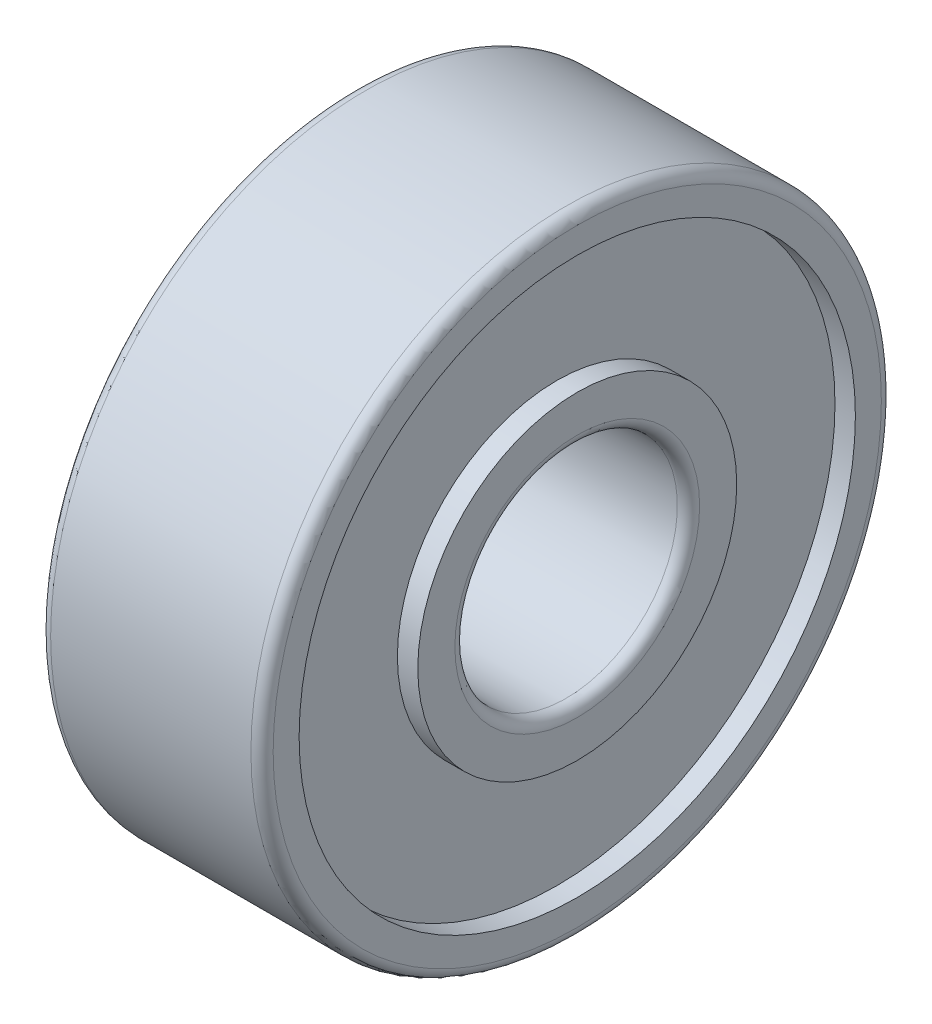
from build123d import *

# Parameters (mm, degrees)
FILLET1_R = 0.3


with BuildPart() as part:
    # Sketch1 → Revolve1 (revolve)
    with BuildSketch(Plane.XY):
        Polygon((0, 3), (6, 3), (6, 4.3), (5.45, 4.3), (5.45, 7.5), (6, 7.5), (6, 8.5), (0, 8.5), (0, 7.5), (0.55, 7.5), (0.55, 4.3), (0, 4.3), align=None)
    revolve(axis=Axis((0, 0, 0), (1, 0, 0)))

    # Fillet1
    fillet1_edges = [part.edges().sort_by_distance(p)[0] for p in [
        (0, -8.5, 0),
        (6, -8.5, 0),
        (6, -3, 0),
        (0, -3, 0),
    ]]
    fillet(fillet1_edges, radius=FILLET1_R)


solid = part.part
